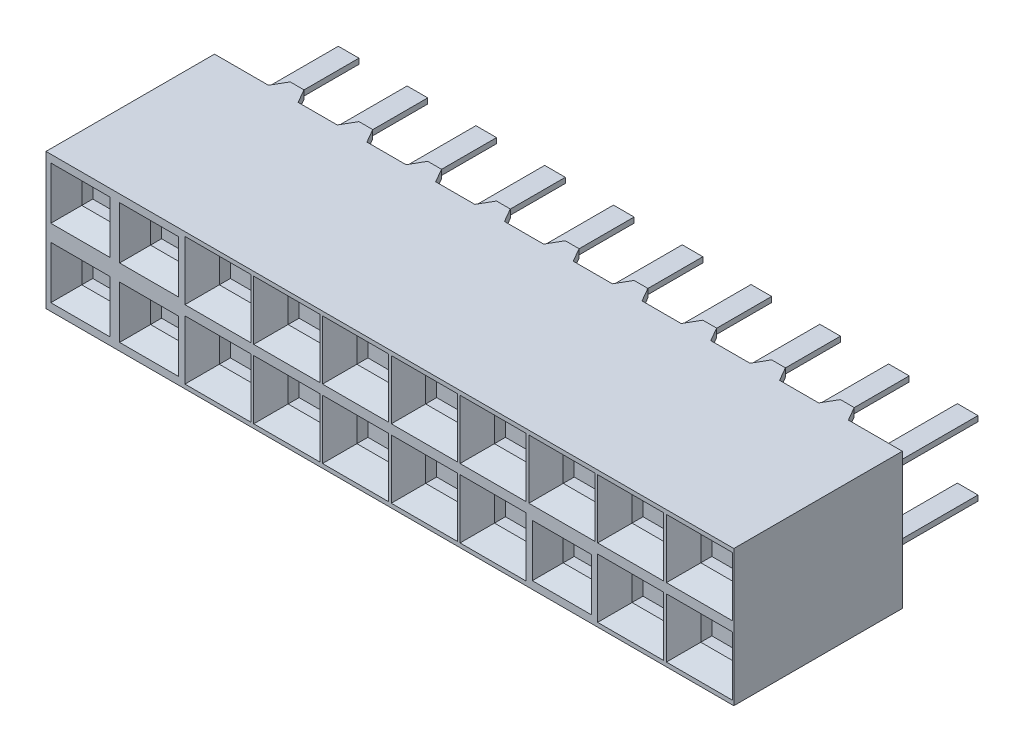
from build123d import *

# Parameters (mm, degrees)
SKETCH1_W            = 25.4
SKETCH1_H            = 6.223
BOSS_EXTRUDE1_DEPTH  = 5.0292
SKETCH2_W            = 1.094587874
SKETCH2_H            = 0.3048
BOSS_EXTRUDE2_DEPTH  = 0.508
SKETCH3_W            = 1.094587874
SKETCH3_H            = 0.3048
BOSS_EXTRUDE3_DEPTH  = 0.508
SKETCH4_W            = 1.094587874
SKETCH4_H            = 0.3048
BOSS_EXTRUDE4_DEPTH  = 0.508
SKETCH5_W            = 1.094587874
SKETCH5_H            = 0.3048
BOSS_EXTRUDE5_DEPTH  = 0.508
SKETCH6_W            = 1.094587874
SKETCH6_H            = 0.3048
BOSS_EXTRUDE6_DEPTH  = 0.508
SKETCH7_W            = 1.094587874
SKETCH7_H            = 0.3048
BOSS_EXTRUDE7_DEPTH  = 0.508
SKETCH8_W            = 1.094587874
SKETCH8_H            = 0.3048
BOSS_EXTRUDE8_DEPTH  = 0.508
SKETCH9_W            = 1.094587874
SKETCH9_H            = 0.3048
BOSS_EXTRUDE9_DEPTH  = 0.508
SKETCH10_W           = 1.094587874
SKETCH10_H           = 0.3048
BOSS_EXTRUDE10_DEPTH = 0.508
SKETCH11_W           = 1.094587874
SKETCH11_H           = 0.3048
BOSS_EXTRUDE11_DEPTH = 0.508
SKETCH12_W           = 1.094587874
SKETCH12_H           = 0.3048
BOSS_EXTRUDE12_DEPTH = 0.508
SKETCH13_W           = 1.094587874
SKETCH13_H           = 0.3048
BOSS_EXTRUDE13_DEPTH = 0.508
SKETCH14_W           = 1.094587874
SKETCH14_H           = 0.3048
BOSS_EXTRUDE14_DEPTH = 0.508
SKETCH15_W           = 1.094587874
SKETCH15_H           = 0.3048
BOSS_EXTRUDE15_DEPTH = 0.508
SKETCH16_W           = 1.094587874
SKETCH16_H           = 0.3048
BOSS_EXTRUDE16_DEPTH = 0.508
SKETCH17_W           = 1.094587874
SKETCH17_H           = 0.3048
BOSS_EXTRUDE17_DEPTH = 0.508
SKETCH18_W           = 1.094587874
SKETCH18_H           = 0.3048
BOSS_EXTRUDE18_DEPTH = 0.508
SKETCH19_W           = 1.094587874
SKETCH19_H           = 0.3048
BOSS_EXTRUDE19_DEPTH = 0.508
DRAFT1_ANGLE         = 30
DRAFT2_ANGLE         = 30
SKETCH20_W           = 0.762
SKETCH20_H           = 0.19812
BOSS_EXTRUDE20_DEPTH = 3.683
SKETCH21_W           = 0.762
SKETCH21_H           = 0.19812
BOSS_EXTRUDE21_DEPTH = 3.683
SKETCH22_W           = 0.762
SKETCH22_H           = 0.19812
BOSS_EXTRUDE22_DEPTH = 3.683
SKETCH23_W           = 0.762
SKETCH23_H           = 0.19812
BOSS_EXTRUDE23_DEPTH = 3.683
SKETCH24_W           = 0.762
SKETCH24_H           = 0.19812
BOSS_EXTRUDE24_DEPTH = 3.683
SKETCH25_W           = 0.762
SKETCH25_H           = 0.19812
BOSS_EXTRUDE25_DEPTH = 3.683
SKETCH26_W           = 0.762
SKETCH26_H           = 0.19812
BOSS_EXTRUDE26_DEPTH = 3.683
SKETCH27_W           = 0.762
SKETCH27_H           = 0.19812
BOSS_EXTRUDE27_DEPTH = 3.683
SKETCH28_W           = 0.762
SKETCH28_H           = 0.19812
BOSS_EXTRUDE28_DEPTH = 3.683
SKETCH29_W           = 0.762
SKETCH29_H           = 0.19812
BOSS_EXTRUDE29_DEPTH = 3.683
SKETCH30_W           = 0.762
SKETCH30_H           = 0.19812
BOSS_EXTRUDE30_DEPTH = 3.683
SKETCH31_W           = 0.762
SKETCH31_H           = 0.19812
BOSS_EXTRUDE31_DEPTH = 3.683
SKETCH32_W           = 0.762
SKETCH32_H           = 0.19812
BOSS_EXTRUDE32_DEPTH = 3.683
SKETCH33_W           = 0.762
SKETCH33_H           = 0.19812
BOSS_EXTRUDE33_DEPTH = 3.683
SKETCH34_W           = 0.762
SKETCH34_H           = 0.19812
BOSS_EXTRUDE34_DEPTH = 3.683
SKETCH35_W           = 0.762
SKETCH35_H           = 0.19812
BOSS_EXTRUDE35_DEPTH = 3.683
SKETCH36_W           = 0.762
SKETCH36_H           = 0.19812
BOSS_EXTRUDE36_DEPTH = 3.683
SKETCH37_W           = 0.762
SKETCH37_H           = 0.19812
BOSS_EXTRUDE37_DEPTH = 3.683
SKETCH38_W           = 0.762
SKETCH38_H           = 0.19812
BOSS_EXTRUDE38_DEPTH = 3.683
SKETCH39_W           = 0.762
SKETCH39_H           = 0.19812
BOSS_EXTRUDE39_DEPTH = 3.683
SKETCH40_W           = 1.1684
SKETCH40_H           = 0.9144
CUT_EXTRUDE1_DEPTH   = 1.0414
LPATTERN1_COUNT      = 2
LPATTERN1_PITCH      = 2.54
LPATTERN1_COUNT_DIR2 = 10
LPATTERN1_PITCH_DIR2 = 2.54
CHAMFER1_SIZE        = 0.635
CHAMFER2_SIZE        = 0.635
CHAMFER3_SIZE        = 0.635
CHAMFER4_SIZE        = 0.635
CHAMFER5_SIZE        = 0.635
CHAMFER6_SIZE        = 0.508
CHAMFER6_SIZE2       = 0.635
CHAMFER7_SIZE        = 0.635
CHAMFER8_SIZE        = 0.635
CHAMFER9_SIZE        = 0.635
CHAMFER10_SIZE       = 0.635
CHAMFER11_SIZE       = 0.635
CHAMFER12_SIZE       = 0.635
CHAMFER13_SIZE       = 0.635
CHAMFER14_SIZE       = 0.635
CHAMFER15_SIZE       = 0.635
CHAMFER16_SIZE       = 0.635
CHAMFER17_SIZE       = 0.508
CHAMFER17_SIZE2      = 0.635
CHAMFER18_SIZE       = 0.508
CHAMFER18_SIZE2      = 0.635
CHAMFER19_SIZE       = 0.508
CHAMFER19_SIZE2      = 0.635
CHAMFER20_SIZE       = 0.508
CHAMFER20_SIZE2      = 0.635


with BuildPart() as part:
    # Sketch1 → Boss-Extrude1 (new body)
    with BuildSketch(Plane(origin=(0, 2.5146, 0), x_dir=(1, 0, 0), z_dir=(0, 1, 0))):
        with Locations((0, -3.1115)):
            Rectangle(SKETCH1_W, SKETCH1_H)
    extrude(amount=-BOSS_EXTRUDE1_DEPTH)

    # Sketch2 → Boss-Extrude2 (add)
    with BuildSketch(Plane(origin=(0, 0, 0), x_dir=(-1, 0, 0), z_dir=(0, 0, -1))):
        with Locations((-7.62, 2.3622)):
            Rectangle(SKETCH2_W, SKETCH2_H)
    extrude(amount=BOSS_EXTRUDE2_DEPTH)

    # Sketch3 → Boss-Extrude3 (add)
    with BuildSketch(Plane(origin=(0, 0, 0), x_dir=(-1, 0, 0), z_dir=(0, 0, -1))):
        with Locations((-5.08, 2.3622)):
            Rectangle(SKETCH3_W, SKETCH3_H)
    extrude(amount=BOSS_EXTRUDE3_DEPTH)

    # Sketch4 → Boss-Extrude4 (add)
    with BuildSketch(Plane(origin=(0, 0, 0), x_dir=(-1, 0, 0), z_dir=(0, 0, -1))):
        with Locations((-2.54, 2.3622)):
            Rectangle(SKETCH4_W, SKETCH4_H)
    extrude(amount=BOSS_EXTRUDE4_DEPTH)

    # Sketch5 → Boss-Extrude5 (add)
    with BuildSketch(Plane(origin=(0, 0, 0), x_dir=(-1, 0, 0), z_dir=(0, 0, -1))):
        with Locations((0, 2.3622)):
            Rectangle(SKETCH5_W, SKETCH5_H)
    extrude(amount=BOSS_EXTRUDE5_DEPTH)

    # Sketch6 → Boss-Extrude6 (add)
    with BuildSketch(Plane(origin=(0, 0, 0), x_dir=(-1, 0, 0), z_dir=(0, 0, -1))):
        with Locations((2.54, 2.3622)):
            Rectangle(SKETCH6_W, SKETCH6_H)
    extrude(amount=BOSS_EXTRUDE6_DEPTH)

    # Sketch7 → Boss-Extrude7 (add)
    with BuildSketch(Plane(origin=(0, 0, 0), x_dir=(-1, 0, 0), z_dir=(0, 0, -1))):
        with Locations((5.08, 2.3622)):
            Rectangle(SKETCH7_W, SKETCH7_H)
    extrude(amount=BOSS_EXTRUDE7_DEPTH)

    # Sketch8 → Boss-Extrude8 (add)
    with BuildSketch(Plane(origin=(0, 0, 0), x_dir=(-1, 0, 0), z_dir=(0, 0, -1))):
        with Locations((7.62, 2.3622)):
            Rectangle(SKETCH8_W, SKETCH8_H)
    extrude(amount=BOSS_EXTRUDE8_DEPTH)

    # Sketch9 → Boss-Extrude9 (add)
    with BuildSketch(Plane(origin=(0, 0, 0), x_dir=(-1, 0, 0), z_dir=(0, 0, -1))):
        with Locations((-10.16, 2.3622)):
            Rectangle(SKETCH9_W, SKETCH9_H)
    extrude(amount=BOSS_EXTRUDE9_DEPTH)

    # Sketch10 → Boss-Extrude10 (add)
    with BuildSketch(Plane(origin=(0, 0, 0), x_dir=(-1, 0, 0), z_dir=(0, 0, -1))):
        with Locations((10.16, -2.3622)):
            Rectangle(SKETCH10_W, SKETCH10_H)
    extrude(amount=BOSS_EXTRUDE10_DEPTH)

    # Sketch11 → Boss-Extrude11 (add)
    with BuildSketch(Plane(origin=(0, 0, 0), x_dir=(-1, 0, 0), z_dir=(0, 0, -1))):
        with Locations((7.62, -2.3622)):
            Rectangle(SKETCH11_W, SKETCH11_H)
    extrude(amount=BOSS_EXTRUDE11_DEPTH)

    # Sketch12 → Boss-Extrude12 (add)
    with BuildSketch(Plane(origin=(0, 0, 0), x_dir=(-1, 0, 0), z_dir=(0, 0, -1))):
        with Locations((5.08, -2.3622)):
            Rectangle(SKETCH12_W, SKETCH12_H)
    extrude(amount=BOSS_EXTRUDE12_DEPTH)

    # Sketch13 → Boss-Extrude13 (add)
    with BuildSketch(Plane(origin=(0, 0, 0), x_dir=(-1, 0, 0), z_dir=(0, 0, -1))):
        with Locations((2.54, -2.3622)):
            Rectangle(SKETCH13_W, SKETCH13_H)
    extrude(amount=BOSS_EXTRUDE13_DEPTH)

    # Sketch14 → Boss-Extrude14 (add)
    with BuildSketch(Plane(origin=(0, 0, 0), x_dir=(-1, 0, 0), z_dir=(0, 0, -1))):
        with Locations((0, -2.3622)):
            Rectangle(SKETCH14_W, SKETCH14_H)
    extrude(amount=BOSS_EXTRUDE14_DEPTH)

    # Sketch15 → Boss-Extrude15 (add)
    with BuildSketch(Plane(origin=(0, 0, 0), x_dir=(-1, 0, 0), z_dir=(0, 0, -1))):
        with Locations((-2.54, -2.3622)):
            Rectangle(SKETCH15_W, SKETCH15_H)
    extrude(amount=BOSS_EXTRUDE15_DEPTH)

    # Sketch16 → Boss-Extrude16 (add)
    with BuildSketch(Plane(origin=(0, 0, 0), x_dir=(-1, 0, 0), z_dir=(0, 0, -1))):
        with Locations((-5.08, -2.3622)):
            Rectangle(SKETCH16_W, SKETCH16_H)
    extrude(amount=BOSS_EXTRUDE16_DEPTH)

    # Sketch17 → Boss-Extrude17 (add)
    with BuildSketch(Plane(origin=(0, 0, 0), x_dir=(-1, 0, 0), z_dir=(0, 0, -1))):
        with Locations((-7.62, -2.3622)):
            Rectangle(SKETCH17_W, SKETCH17_H)
    extrude(amount=BOSS_EXTRUDE17_DEPTH)

    # Sketch18 → Boss-Extrude18 (add)
    with BuildSketch(Plane(origin=(0, 0, 0), x_dir=(-1, 0, 0), z_dir=(0, 0, -1))):
        with Locations((-10.16, -2.3622)):
            Rectangle(SKETCH18_W, SKETCH18_H)
    extrude(amount=BOSS_EXTRUDE18_DEPTH)

    # Sketch19 → Boss-Extrude19 (add)
    with BuildSketch(Plane(origin=(0, 0, 0), x_dir=(-1, 0, 0), z_dir=(0, 0, -1))):
        with Locations((10.16, 2.3622)):
            Rectangle(SKETCH19_W, SKETCH19_H)
    extrude(amount=BOSS_EXTRUDE19_DEPTH)

    # Draft1
    draft1_faces = [part.faces().sort_by_distance(p)[0] for p in [
        (-4.532706063, 2.3622, -0.254),
        (-7.072706063, 2.3622, -0.254),
        (-9.612706063, 2.3622, -0.254),
        (-9.612706063, -2.3622, -0.254),
        (-7.072706063, -2.3622, -0.254),
        (-4.532706063, -2.3622, -0.254),
        (-1.992706063, 2.3622, -0.254),
        (-1.992706063, -2.3622, -0.254),
        (0.547293937, -2.3622, -0.254),
        (0.547293937, 2.3622, -0.254),
        (3.087293937, 2.3622, -0.254),
        (3.087293937, -2.3622, -0.254),
        (5.627293937, -2.3622, -0.254),
        (5.627293937, 2.3622, -0.254),
        (8.167293937, 2.3622, -0.254),
        (8.167293937, -2.3622, -0.254),
        (10.707293937, -2.3622, -0.254),
        (10.707293937, 2.3622, -0.254),
    ]]
    draft(draft1_faces, Plane(origin=(12.7, -2.5146, 0), x_dir=(-1, 0, 0), z_dir=(0, 0, -1)), DRAFT1_ANGLE)

    # Draft2
    draft2_faces = [part.faces().sort_by_distance(p)[0] for p in [
        (9.612706063, 2.3622, -0.254),
        (9.612706063, -2.3622, -0.254),
        (7.072706063, 2.3622, -0.254),
        (7.072706063, -2.3622, -0.254),
        (4.532706063, 2.3622, -0.254),
        (1.992706063, 2.3622, -0.254),
        (1.992706063, -2.3622, -0.254),
        (4.532706063, -2.3622, -0.254),
        (-0.547293937, 2.3622, -0.254),
        (-0.547293937, -2.3622, -0.254),
        (-3.087293937, 2.3622, -0.254),
        (-3.087293937, -2.3622, -0.254),
        (-5.627293937, 2.3622, -0.254),
        (-5.627293937, -2.3622, -0.254),
        (-8.167293937, 2.3622, -0.254),
        (-8.167293937, -2.3622, -0.254),
        (-10.707293937, 2.3622, -0.254),
        (-10.707293937, -2.3622, -0.254),
    ]]
    draft(draft2_faces, Plane(origin=(12.7, -2.5146, 0), x_dir=(-1, 0, 0), z_dir=(0, 0, -1)), DRAFT2_ANGLE)

    # Sketch20 → Boss-Extrude20 (add)
    with BuildSketch(Plane(origin=(0, 0, 0), x_dir=(-1, 0, 0), z_dir=(0, 0, -1))):
        with Locations((-11.43, -1.27)):
            Rectangle(SKETCH20_W, SKETCH20_H)
    extrude(amount=BOSS_EXTRUDE20_DEPTH)

    # Sketch21 → Boss-Extrude21 (add)
    with BuildSketch(Plane(origin=(0, 0, 0), x_dir=(-1, 0, 0), z_dir=(0, 0, -1))):
        with Locations((-11.43, 1.27)):
            Rectangle(SKETCH21_W, SKETCH21_H)
    extrude(amount=BOSS_EXTRUDE21_DEPTH)

    # Sketch22 → Boss-Extrude22 (add)
    with BuildSketch(Plane(origin=(0, 0, 0), x_dir=(-1, 0, 0), z_dir=(0, 0, -1))):
        with Locations((-8.89, -1.27)):
            Rectangle(SKETCH22_W, SKETCH22_H)
    extrude(amount=BOSS_EXTRUDE22_DEPTH)

    # Sketch23 → Boss-Extrude23 (add)
    with BuildSketch(Plane(origin=(0, 0, 0), x_dir=(-1, 0, 0), z_dir=(0, 0, -1))):
        with Locations((-8.89, 1.27)):
            Rectangle(SKETCH23_W, SKETCH23_H)
    extrude(amount=BOSS_EXTRUDE23_DEPTH)

    # Sketch24 → Boss-Extrude24 (add)
    with BuildSketch(Plane(origin=(0, 0, 0), x_dir=(-1, 0, 0), z_dir=(0, 0, -1))):
        with Locations((-6.35, -1.27)):
            Rectangle(SKETCH24_W, SKETCH24_H)
    extrude(amount=BOSS_EXTRUDE24_DEPTH)

    # Sketch25 → Boss-Extrude25 (add)
    with BuildSketch(Plane(origin=(0, 0, 0), x_dir=(-1, 0, 0), z_dir=(0, 0, -1))):
        with Locations((-6.35, 1.27)):
            Rectangle(SKETCH25_W, SKETCH25_H)
    extrude(amount=BOSS_EXTRUDE25_DEPTH)

    # Sketch26 → Boss-Extrude26 (add)
    with BuildSketch(Plane(origin=(0, 0, 0), x_dir=(-1, 0, 0), z_dir=(0, 0, -1))):
        with Locations((-3.81, -1.27)):
            Rectangle(SKETCH26_W, SKETCH26_H)
    extrude(amount=BOSS_EXTRUDE26_DEPTH)

    # Sketch27 → Boss-Extrude27 (add)
    with BuildSketch(Plane(origin=(0, 0, 0), x_dir=(-1, 0, 0), z_dir=(0, 0, -1))):
        with Locations((-3.81, 1.27)):
            Rectangle(SKETCH27_W, SKETCH27_H)
    extrude(amount=BOSS_EXTRUDE27_DEPTH)

    # Sketch28 → Boss-Extrude28 (add)
    with BuildSketch(Plane(origin=(0, 0, 0), x_dir=(-1, 0, 0), z_dir=(0, 0, -1))):
        with Locations((-1.27, -1.27)):
            Rectangle(SKETCH28_W, SKETCH28_H)
    extrude(amount=BOSS_EXTRUDE28_DEPTH)

    # Sketch29 → Boss-Extrude29 (add)
    with BuildSketch(Plane(origin=(0, 0, 0), x_dir=(-1, 0, 0), z_dir=(0, 0, -1))):
        with Locations((-1.27, 1.27)):
            Rectangle(SKETCH29_W, SKETCH29_H)
    extrude(amount=BOSS_EXTRUDE29_DEPTH)

    # Sketch30 → Boss-Extrude30 (add)
    with BuildSketch(Plane(origin=(0, 0, 0), x_dir=(-1, 0, 0), z_dir=(0, 0, -1))):
        with Locations((1.27, -1.27)):
            Rectangle(SKETCH30_W, SKETCH30_H)
    extrude(amount=BOSS_EXTRUDE30_DEPTH)

    # Sketch31 → Boss-Extrude31 (add)
    with BuildSketch(Plane(origin=(0, 0, 0), x_dir=(-1, 0, 0), z_dir=(0, 0, -1))):
        with Locations((1.27, 1.27)):
            Rectangle(SKETCH31_W, SKETCH31_H)
    extrude(amount=BOSS_EXTRUDE31_DEPTH)

    # Sketch32 → Boss-Extrude32 (add)
    with BuildSketch(Plane(origin=(0, 0, 0), x_dir=(-1, 0, 0), z_dir=(0, 0, -1))):
        with Locations((3.81, -1.27)):
            Rectangle(SKETCH32_W, SKETCH32_H)
    extrude(amount=BOSS_EXTRUDE32_DEPTH)

    # Sketch33 → Boss-Extrude33 (add)
    with BuildSketch(Plane(origin=(0, 0, 0), x_dir=(-1, 0, 0), z_dir=(0, 0, -1))):
        with Locations((3.81, 1.27)):
            Rectangle(SKETCH33_W, SKETCH33_H)
    extrude(amount=BOSS_EXTRUDE33_DEPTH)

    # Sketch34 → Boss-Extrude34 (add)
    with BuildSketch(Plane(origin=(0, 0, 0), x_dir=(-1, 0, 0), z_dir=(0, 0, -1))):
        with Locations((6.35, -1.27)):
            Rectangle(SKETCH34_W, SKETCH34_H)
    extrude(amount=BOSS_EXTRUDE34_DEPTH)

    # Sketch35 → Boss-Extrude35 (add)
    with BuildSketch(Plane(origin=(0, 0, 0), x_dir=(-1, 0, 0), z_dir=(0, 0, -1))):
        with Locations((6.35, 1.27)):
            Rectangle(SKETCH35_W, SKETCH35_H)
    extrude(amount=BOSS_EXTRUDE35_DEPTH)

    # Sketch36 → Boss-Extrude36 (add)
    with BuildSketch(Plane(origin=(0, 0, 0), x_dir=(-1, 0, 0), z_dir=(0, 0, -1))):
        with Locations((8.89, -1.27)):
            Rectangle(SKETCH36_W, SKETCH36_H)
    extrude(amount=BOSS_EXTRUDE36_DEPTH)

    # Sketch37 → Boss-Extrude37 (add)
    with BuildSketch(Plane(origin=(0, 0, 0), x_dir=(-1, 0, 0), z_dir=(0, 0, -1))):
        with Locations((8.89, 1.27)):
            Rectangle(SKETCH37_W, SKETCH37_H)
    extrude(amount=BOSS_EXTRUDE37_DEPTH)

    # Sketch38 → Boss-Extrude38 (add)
    with BuildSketch(Plane(origin=(0, 0, 0), x_dir=(-1, 0, 0), z_dir=(0, 0, -1))):
        with Locations((11.43, 1.27)):
            Rectangle(SKETCH38_W, SKETCH38_H)
    extrude(amount=BOSS_EXTRUDE38_DEPTH)

    # Sketch39 → Boss-Extrude39 (add)
    with BuildSketch(Plane(origin=(0, 0, 0), x_dir=(-1, 0, 0), z_dir=(0, 0, -1))):
        with Locations((11.43, -1.27)):
            Rectangle(SKETCH39_W, SKETCH39_H)
    extrude(amount=BOSS_EXTRUDE39_DEPTH)

    # Sketch40 → Cut-Extrude1 (cut)
    with BuildSketch(Plane.XY.offset(6.223)):
        with Locations((-11.43, -1.27)):
            Rectangle(SKETCH40_W, SKETCH40_H)
    cut_extrude1 = extrude(amount=-CUT_EXTRUDE1_DEPTH, mode=Mode.SUBTRACT)

    # LPattern1: Cut-Extrude1 2 × 10
    with Locations(*[(j * LPATTERN1_PITCH_DIR2, i * LPATTERN1_PITCH, 0) for i in range(LPATTERN1_COUNT) for j in range(LPATTERN1_COUNT_DIR2) if (i, j) != (0, 0)]):
        add(cut_extrude1, mode=Mode.SUBTRACT)

    # Chamfer1
    chamfer1_edges = [part.edges().sort_by_distance(p)[0] for p in [
        (10.8458, -1.27, 6.223),
        (11.43, -0.8128, 6.223),
        (12.0142, -1.27, 6.223),
        (11.43, -1.7272, 6.223),
    ]]
    chamfer(chamfer1_edges, length=CHAMFER1_SIZE)

    # Chamfer2
    chamfer2_edges = [part.edges().sort_by_distance(p)[0] for p in [
        (10.8458, 1.27, 6.223),
        (11.43, 1.7272, 6.223),
        (12.0142, 1.27, 6.223),
        (11.43, 0.8128, 6.223),
    ]]
    chamfer(chamfer2_edges, length=CHAMFER2_SIZE)

    # Chamfer3
    chamfer3_edges = [part.edges().sort_by_distance(p)[0] for p in [
        (8.3058, -1.27, 6.223),
        (8.89, -0.8128, 6.223),
        (9.4742, -1.27, 6.223),
        (8.89, -1.7272, 6.223),
    ]]
    chamfer(chamfer3_edges, length=CHAMFER3_SIZE)

    # Chamfer4
    chamfer4_edges = [part.edges().sort_by_distance(p)[0] for p in [
        (8.3058, 1.27, 6.223),
        (8.89, 1.7272, 6.223),
        (9.4742, 1.27, 6.223),
        (8.89, 0.8128, 6.223),
    ]]
    chamfer(chamfer4_edges, length=CHAMFER4_SIZE)

    # Chamfer5
    chamfer5_edges = [part.edges().sort_by_distance(p)[0] for p in [
        (5.7658, 1.27, 6.223),
        (6.35, 1.7272, 6.223),
        (6.9342, 1.27, 6.223),
        (6.35, 0.8128, 6.223),
    ]]
    chamfer(chamfer5_edges, length=CHAMFER5_SIZE)

    # Chamfer6
    chamfer6_edges = [part.edges().sort_by_distance(p)[0] for p in [
        (5.7658, -1.27, 6.223),
        (6.35, -0.8128, 6.223),
        (6.9342, -1.27, 6.223),
        (6.35, -1.7272, 6.223),
    ]]
    chamfer6_side = [part.faces().sort_by_distance(p)[0] for p in [
        (-2.351637853, -0.06355778, 6.223),
    ]]
    chamfer(chamfer6_edges, length=CHAMFER6_SIZE, length2=CHAMFER6_SIZE2, reference=chamfer6_side[0])

    # Chamfer7
    chamfer7_edges = [part.edges().sort_by_distance(p)[0] for p in [
        (3.2258, -1.27, 6.223),
        (3.81, -0.8128, 6.223),
        (4.3942, -1.27, 6.223),
        (3.81, -1.7272, 6.223),
    ]]
    chamfer(chamfer7_edges, length=CHAMFER7_SIZE)

    # Chamfer8
    chamfer8_edges = [part.edges().sort_by_distance(p)[0] for p in [
        (3.2258, 1.27, 6.223),
        (3.81, 1.7272, 6.223),
        (4.3942, 1.27, 6.223),
        (3.81, 0.8128, 6.223),
    ]]
    chamfer(chamfer8_edges, length=CHAMFER8_SIZE)

    # Chamfer9
    chamfer9_edges = [part.edges().sort_by_distance(p)[0] for p in [
        (0.6858, -1.27, 6.223),
        (1.27, -0.8128, 6.223),
        (1.8542, -1.27, 6.223),
        (1.27, -1.7272, 6.223),
    ]]
    chamfer(chamfer9_edges, length=CHAMFER9_SIZE)

    # Chamfer10
    chamfer10_edges = [part.edges().sort_by_distance(p)[0] for p in [
        (0.6858, 1.27, 6.223),
        (1.27, 1.7272, 6.223),
        (1.8542, 1.27, 6.223),
        (1.27, 0.8128, 6.223),
    ]]
    chamfer(chamfer10_edges, length=CHAMFER10_SIZE)

    # Chamfer11
    chamfer11_edges = [part.edges().sort_by_distance(p)[0] for p in [
        (-1.8542, -1.27, 6.223),
        (-1.27, -0.8128, 6.223),
        (-0.6858, -1.27, 6.223),
        (-1.27, -1.7272, 6.223),
    ]]
    chamfer(chamfer11_edges, length=CHAMFER11_SIZE)

    # Chamfer12
    chamfer12_edges = [part.edges().sort_by_distance(p)[0] for p in [
        (-1.8542, 1.27, 6.223),
        (-1.27, 1.7272, 6.223),
        (-0.6858, 1.27, 6.223),
        (-1.27, 0.8128, 6.223),
    ]]
    chamfer(chamfer12_edges, length=CHAMFER12_SIZE)

    # Chamfer13
    chamfer13_edges = [part.edges().sort_by_distance(p)[0] for p in [
        (-4.3942, -1.27, 6.223),
        (-3.81, -0.8128, 6.223),
        (-3.2258, -1.27, 6.223),
        (-3.81, -1.7272, 6.223),
    ]]
    chamfer(chamfer13_edges, length=CHAMFER13_SIZE)

    # Chamfer14
    chamfer14_edges = [part.edges().sort_by_distance(p)[0] for p in [
        (-4.3942, 1.27, 6.223),
        (-3.81, 1.7272, 6.223),
        (-3.2258, 1.27, 6.223),
        (-3.81, 0.8128, 6.223),
    ]]
    chamfer(chamfer14_edges, length=CHAMFER14_SIZE)

    # Chamfer15
    chamfer15_edges = [part.edges().sort_by_distance(p)[0] for p in [
        (-6.9342, -1.27, 6.223),
        (-6.35, -0.8128, 6.223),
        (-5.7658, -1.27, 6.223),
        (-6.35, -1.7272, 6.223),
    ]]
    chamfer(chamfer15_edges, length=CHAMFER15_SIZE)

    # Chamfer16
    chamfer16_edges = [part.edges().sort_by_distance(p)[0] for p in [
        (-6.9342, 1.27, 6.223),
        (-6.35, 1.7272, 6.223),
        (-5.7658, 1.27, 6.223),
        (-6.35, 0.8128, 6.223),
    ]]
    chamfer(chamfer16_edges, length=CHAMFER16_SIZE)

    # Chamfer17
    chamfer17_edges = [part.edges().sort_by_distance(p)[0] for p in [
        (-9.4742, 1.27, 6.223),
        (-8.89, 1.7272, 6.223),
        (-8.3058, 1.27, 6.223),
        (-8.89, 0.8128, 6.223),
    ]]
    chamfer17_side = [part.faces().sort_by_distance(p)[0] for p in [
        (-4.218065574, -0.035809836, 6.223),
    ]]
    chamfer(chamfer17_edges, length=CHAMFER17_SIZE, length2=CHAMFER17_SIZE2, reference=chamfer17_side[0])

    # Chamfer18
    chamfer18_edges = [part.edges().sort_by_distance(p)[0] for p in [
        (-9.4742, -1.27, 6.223),
        (-8.89, -0.8128, 6.223),
        (-8.3058, -1.27, 6.223),
        (-8.89, -1.7272, 6.223),
    ]]
    chamfer18_side = [part.faces().sort_by_distance(p)[0] for p in [
        (-3.811810406, -0.149358517, 6.223),
    ]]
    chamfer(chamfer18_edges, length=CHAMFER18_SIZE, length2=CHAMFER18_SIZE2, reference=chamfer18_side[0])

    # Chamfer19
    chamfer19_edges = [part.edges().sort_by_distance(p)[0] for p in [
        (-12.0142, 1.27, 6.223),
        (-11.43, 0.8128, 6.223),
        (-10.8458, 1.27, 6.223),
        (-11.43, 1.7272, 6.223),
    ]]
    chamfer19_side = [part.faces().sort_by_distance(p)[0] for p in [
        (-3.328173302, -0.042630757, 6.223),
    ]]
    chamfer(chamfer19_edges, length=CHAMFER19_SIZE, length2=CHAMFER19_SIZE2, reference=chamfer19_side[0])

    # Chamfer20
    chamfer20_edges = [part.edges().sort_by_distance(p)[0] for p in [
        (-12.0142, -1.27, 6.223),
        (-11.43, -1.7272, 6.223),
        (-10.8458, -1.27, 6.223),
        (-11.43, -0.8128, 6.223),
    ]]
    chamfer20_side = [part.faces().sort_by_distance(p)[0] for p in [
        (-12.548093104, 1.27, 6.223),
    ]]
    chamfer(chamfer20_edges, length=CHAMFER20_SIZE, length2=CHAMFER20_SIZE2, reference=chamfer20_side[0])


solid = part.part
